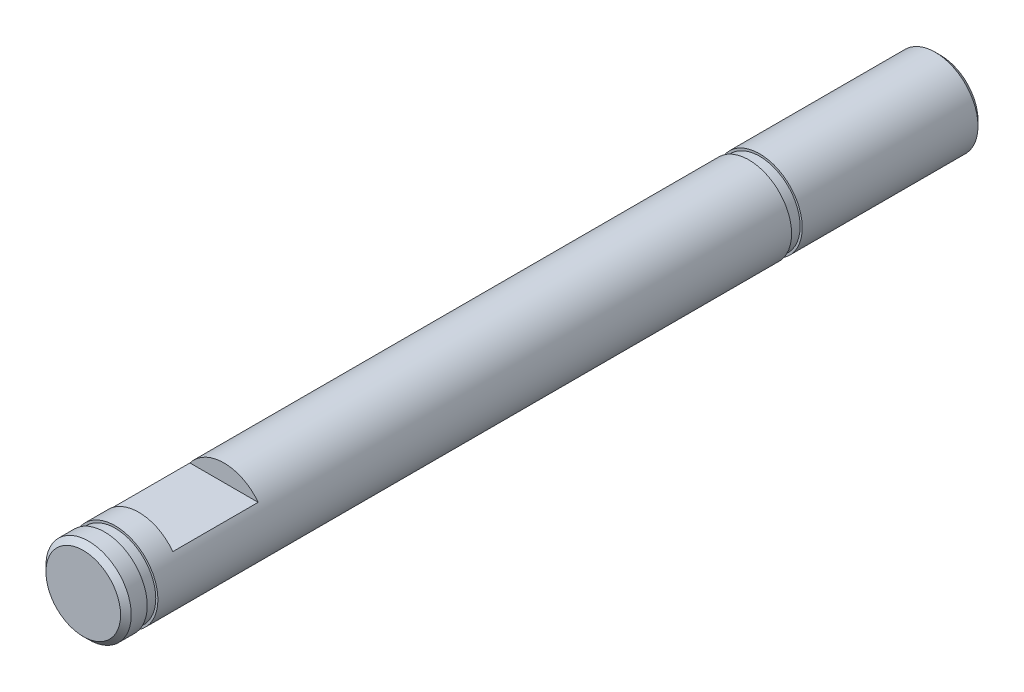
from build123d import *

# Parameters (mm, degrees)
CIRCLE_R                     = 2
BOSS_EXTRU_1_DEPTH           = 40.2
ENL_V_MAT_EXTRU_1_DEPTH      = 4
ENL_V_MAT_EXTRU_2_DEPTH      = 5
GORGECIRCLIPPOLULU_OUTSIDE_W = 14.12
GORGECIRCLIPPOLULU_OUTSIDE_H = 14.12
GORGECIRCLIPPOLULU_OUTSIDE_R = 1.9
ENL_V_MAT_EXTRU_3_DEPTH      = 0.5
ESQUISSE1_OUTSIDE_W          = 14.12
ESQUISSE1_OUTSIDE_H          = 14.12
ESQUISSE1_OUTSIDE_R          = 1.9
ENL_V_MAT_EXTRU_4_DEPTH      = 0.5
CHANFREIN1_SIZE              = 0.25
CHANFREIN2_SIZE              = 0.25


with BuildPart() as part:
    # Circle → Boss.-Extru.1 (new body)
    with BuildSketch(Plane.XY):
        Circle(CIRCLE_R)
    extrude(amount=BOSS_EXTRU_1_DEPTH)

    # MeplatPololu → Enlèv. mat.-Extru.1 (cut)
    with BuildSketch(Plane.XY.offset(37.6)):
        with BuildLine():
            Line((-1.6, 1.2), (1.6, 1.2))
            ThreePointArc((1.6, 1.2), (0, 2), (-1.6, 1.2))
        make_face()
    extrude(amount=-ENL_V_MAT_EXTRU_1_DEPTH, mode=Mode.SUBTRACT)

    # MeplatRoueDentee → Enlèv. mat.-Extru.2 (cut)
    with BuildSketch(Plane.XY.offset(17.09)):
        with BuildLine():
            Line((0.164576352, -1.993217154), (-1.959569847, 0.400107505))
            ThreePointArc((-1.959569847, 0.400107505), (-1.495827912, -1.327591374), (0.164576352, -1.993217154))
        make_face()
    extrude(amount=-ENL_V_MAT_EXTRU_2_DEPTH, mode=Mode.SUBTRACT)

    # GorgeCirclipPolulu outside → Enlèv. mat.-Extru.3 (cut)
    with BuildSketch(Plane.XY.offset(38.7)):
        Rectangle(GORGECIRCLIPPOLULU_OUTSIDE_W, GORGECIRCLIPPOLULU_OUTSIDE_H)
        Circle(GORGECIRCLIPPOLULU_OUTSIDE_R, mode=Mode.SUBTRACT)
    extrude(amount=ENL_V_MAT_EXTRU_3_DEPTH, mode=Mode.SUBTRACT)

    # Esquisse1 outside → Enlèv. mat.-Extru.4 (cut)
    with BuildSketch(Plane.XY.offset(8.99)):
        Rectangle(ESQUISSE1_OUTSIDE_W, ESQUISSE1_OUTSIDE_H)
        Circle(ESQUISSE1_OUTSIDE_R, mode=Mode.SUBTRACT)
    extrude(amount=-ENL_V_MAT_EXTRU_4_DEPTH, mode=Mode.SUBTRACT)

    # Chanfrein1
    chanfrein1_edges = [part.edges().sort_by_distance(p)[0] for p in [
        (-2, 0, 40.2),
    ]]
    chamfer(chanfrein1_edges, length=CHANFREIN1_SIZE)

    # Chanfrein2
    chanfrein2_edges = [part.edges().sort_by_distance(p)[0] for p in [
        (-2, 0, 0),
    ]]
    chamfer(chanfrein2_edges, length=CHANFREIN2_SIZE)


solid = part.part
